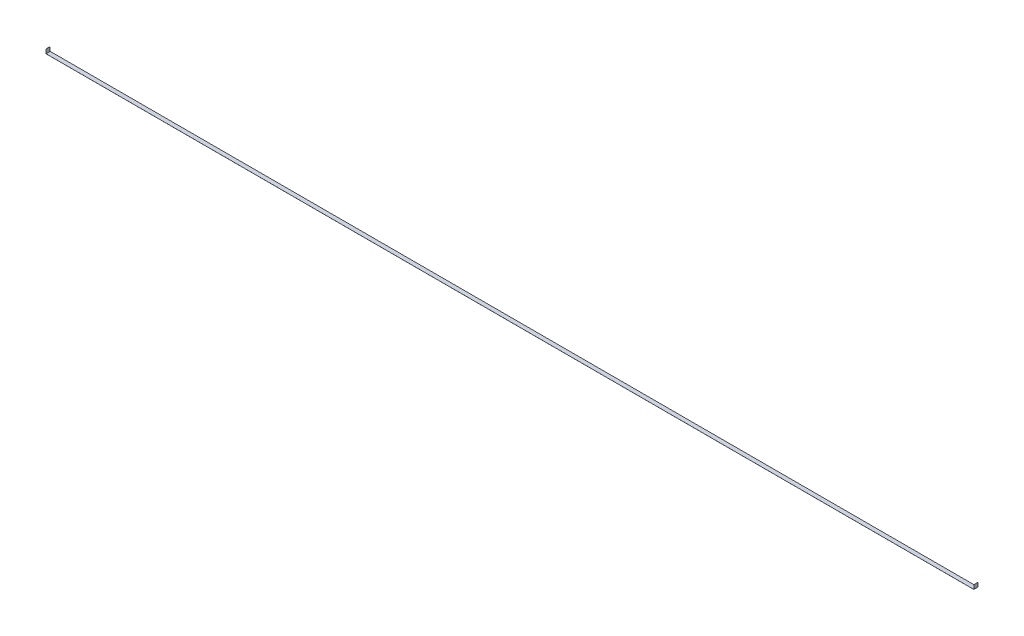
from build123d import *

# Parameters (mm, degrees)
EXTRUDE_THIN1_DEPTH = 12.7


with BuildPart() as part:
    # Sketch1 → Extrude-Thin1 (new body, symmetric)
    with BuildSketch(Plane.XY):
        Polygon((-2832.1, 25.4), (-2832.1, 0), (2832.1, 0), (2832.1, 25.4), (2832.354, 25.4), (2832.354, -0.254), (-2832.354, -0.254), (-2832.354, 25.4), align=None)
    extrude(amount=EXTRUDE_THIN1_DEPTH, both=True)


solid = part.part
